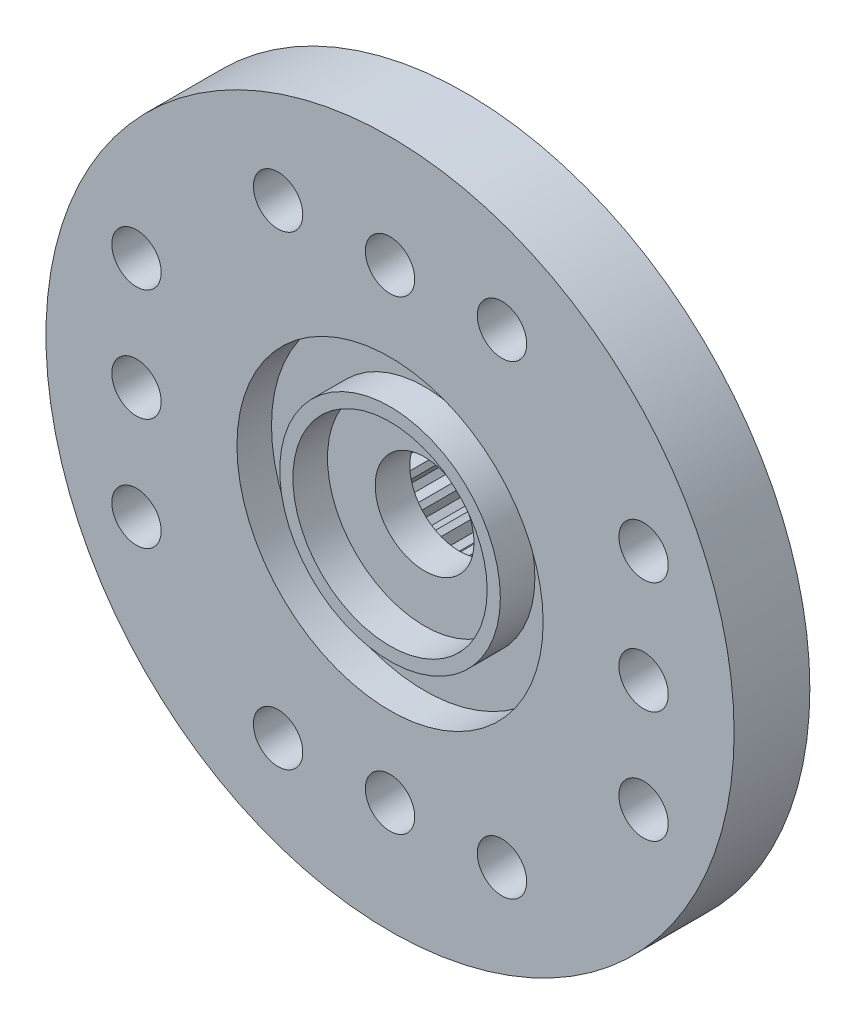
from build123d import *

# Parameters (mm, degrees)
IZIM1_R                     = 4.45
Y_KSEKLIK_EKSTR_ZYON1_DEPTH = 5.6
IZIM2_R                     = 10.45
IZIM2_R_2                   = 0.75
Y_KSEKLIK_EKSTR_ZYON2_DEPTH = 2.3
IZIM3_R                     = 2.95
KES_EKSTR_ZYON1_DEPTH       = 1.05
IZIM4_R                     = 4.65
IZIM4_R_2                   = 3.35
KES_EKSTR_ZYON2_DEPTH       = 1.05
IZIM5_R                     = 1.5
KES_EKSTR_ZYON3_DEPTH       = 11.05
IZIM6_R                     = 2.68
KES_EKSTR_ZYON4_DEPTH       = 3.5
KES_EKSTR_ZYON5_DEPTH       = 3.5
DAIRESEL_KAPLAMA1_COUNT     = 24


with BuildPart() as part:
    # Çizim1 → Yükseklik-Ekstrüzyon1 (new body)
    with BuildSketch(Plane.XY):
        Circle(IZIM1_R)
    extrude(amount=Y_KSEKLIK_EKSTR_ZYON1_DEPTH)

    # Çizim2 → Yükseklik-Ekstrüzyon2 (add)
    with BuildSketch(Plane.XY.offset(5.6)):
        Circle(IZIM2_R)
        with Locations((-7.7, 3.4)):
            Circle(IZIM2_R_2, mode=Mode.SUBTRACT)
        with Locations((-7.7, 0)):
            Circle(IZIM2_R_2, mode=Mode.SUBTRACT)
        with Locations((-7.7, -3.4)):
            Circle(IZIM2_R_2, mode=Mode.SUBTRACT)
        with Locations((0, 7.07)):
            Circle(IZIM2_R_2, mode=Mode.SUBTRACT)
        with Locations((3.4, 7.07)):
            Circle(IZIM2_R_2, mode=Mode.SUBTRACT)
        with Locations((-3.4, 7.07)):
            Circle(IZIM2_R_2, mode=Mode.SUBTRACT)
        with Locations(Location((-3.4, -7.07, 0), (0, 0, 180))):
            Circle(IZIM2_R_2, mode=Mode.SUBTRACT)
        with Locations(Location((3.4, -7.07, 0), (0, 0, 180))):
            Circle(IZIM2_R_2, mode=Mode.SUBTRACT)
        with Locations(Location((0, -7.07, 0), (0, 0, 180))):
            Circle(IZIM2_R_2, mode=Mode.SUBTRACT)
        with Locations(Location((7.7, -3.4, 0), (0, 0, 180))):
            Circle(IZIM2_R_2, mode=Mode.SUBTRACT)
        with Locations(Location((7.7, 0, 0), (0, 0, 180))):
            Circle(IZIM2_R_2, mode=Mode.SUBTRACT)
        with Locations(Location((7.7, 3.4, 0), (0, 0, 180))):
            Circle(IZIM2_R_2, mode=Mode.SUBTRACT)
    extrude(amount=-Y_KSEKLIK_EKSTR_ZYON2_DEPTH)

    # Çizim3 → Kes-Ekstrüzyon1 (cut)
    with BuildSketch(Plane.XY.offset(5.6)):
        Circle(IZIM3_R)
    extrude(amount=-KES_EKSTR_ZYON1_DEPTH, mode=Mode.SUBTRACT)

    # Çizim4 → Kes-Ekstrüzyon2 (cut)
    with BuildSketch(Plane.XY.offset(5.6)):
        Circle(IZIM4_R)
        Circle(IZIM4_R_2, mode=Mode.SUBTRACT)
    extrude(amount=-KES_EKSTR_ZYON2_DEPTH, mode=Mode.SUBTRACT)

    # Çizim5 → Kes-Ekstrüzyon3 (cut)
    with BuildSketch(Plane.XY.offset(4.55)):
        Circle(IZIM5_R)
    extrude(amount=-KES_EKSTR_ZYON3_DEPTH, mode=Mode.SUBTRACT)

    # Çizim6 → Kes-Ekstrüzyon4 (cut)
    with BuildSketch(Plane(origin=(0, 0, 0), x_dir=(-1, 0, 0), z_dir=(0, 0, -1))):
        Circle(IZIM6_R)
    extrude(amount=-KES_EKSTR_ZYON4_DEPTH, mode=Mode.SUBTRACT)

    # Çizim7 → Kes-Ekstrüzyon5 (cut)
    with BuildSketch(Plane(origin=(0, 0, 3.5), x_dir=(-1, 0, 0), z_dir=(0, 0, -1))):
        with BuildLine():
            Line((-2.485339529, 1.767933095), (-2.601102839, 1.592722205))
            Line((-2.601102839, 1.592722205), (-2.368659359, 1.253735555))
            ThreePointArc((-2.368659359, 1.253735555), (-2.236024692, 1.477360341), (-2.082344793, 1.687080366))
            Line((-2.082344793, 1.687080366), (-2.485339529, 1.767933095))
        make_face()
    kes_ekstr_zyon5 = extrude(amount=KES_EKSTR_ZYON5_DEPTH, mode=Mode.SUBTRACT)

    # Dairesel Kaplama1: Kes-Ekstrüzyon5 ×24 about axis
    dairesel_kaplama1_axis = Axis((0, 0, 0), (0, 0, 1))
    for i in range(1, DAIRESEL_KAPLAMA1_COUNT):
        add(kes_ekstr_zyon5.rotate(dairesel_kaplama1_axis, i * 360 / DAIRESEL_KAPLAMA1_COUNT), mode=Mode.SUBTRACT)


solid = part.part
